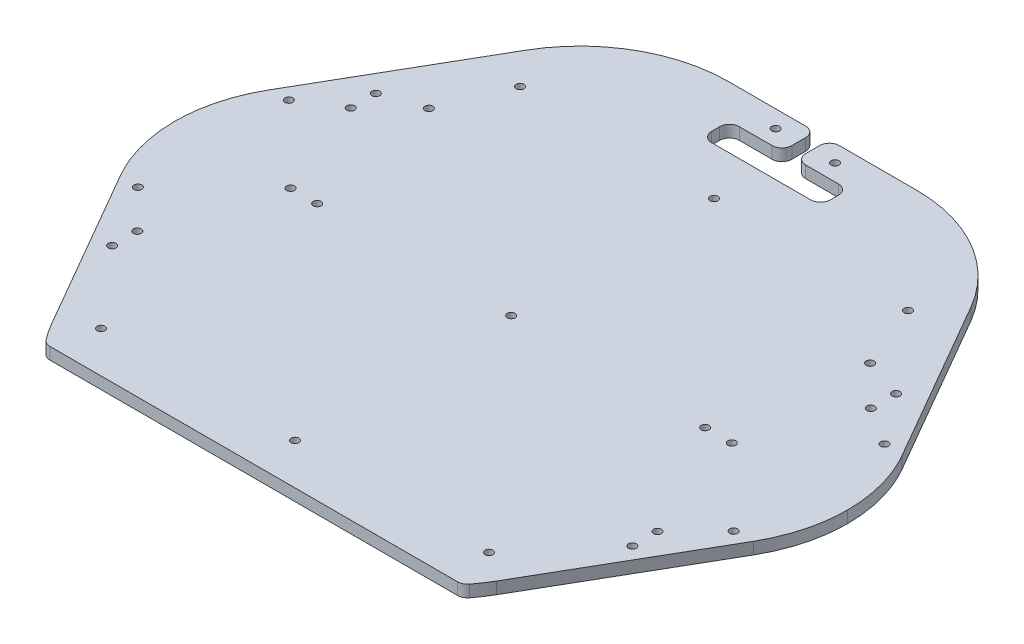
from build123d import *

# Parameters (mm, degrees)
BOSS_EXTRUDE1_DEPTH        = 6
CUT_EXTRUDE1_DEPTH         = 7.0000001
M3_5_CLEARANCE_HOLE1_D     = 3.949564791
M3_5_CLEARANCE_HOLE1_DEPTH = 6.000055
FILLET1_R                  = 5.02065441
FILLET2_R                  = 74.958489821


with BuildPart() as part:
    # Sketch1 → Boss-Extrude1 (new body)
    with BuildSketch(Plane(origin=(0, 6, 0), x_dir=(1, 0, 0), z_dir=(0, 1, 0))):
        with BuildLine():
            Line((112.451900879, -119.772412512), (159.951903815, -37.500000848))
            add(Edge.make_bspline(
                [(159.951903815, -37.500000848), (162.089841538, -33.796778918), (165.842589826, -25.786061926), (169.244511458, -13.089917553), (169.999894602, -4.276058992), (169.999997188, -5.864e-06)],
                knots=[2.617993882, 2.617993882, 2.617993882, 2.617993882, 2.789036145, 2.970550387, 3.141592649, 3.141592649, 3.141592649, 3.141592649], degree=3))
            add(Edge.make_bspline(
                [(169.999997188, -5.864e-06), (169.999894602, 4.276047264), (169.244511458, 13.089905825), (165.842589826, 25.786050198), (162.089841538, 33.79676719), (159.951903815, 37.49998912)],
                knots=[3.141592658, 3.141592658, 3.141592658, 3.141592658, 3.31263492, 3.494149162, 3.665191425, 3.665191425, 3.665191425, 3.665191425], degree=3))
            Line((159.951903815, 37.49998912), (90.801278878, 157.272408343))
            Line((90.801278878, 157.272408343), (-90.8012615, 157.272408343))
            Line((-90.8012615, 157.272408343), (-159.951896595, 37.499994984))
            add(Edge.make_bspline(
                [(-159.951896595, 37.499994984), (-162.089834317, 33.796773054), (-165.842582605, 25.786056062), (-169.244504237, 13.08991169), (-169.999887381, 4.276053128), (-169.999989967, 0)],
                knots=[5.759586536, 5.759586536, 5.759586536, 5.759586536, 5.930628798, 6.11214304, 6.283185303, 6.283185303, 6.283185303, 6.283185303], degree=3))
            add(Edge.make_bspline(
                [(-169.999989967, 0), (-169.999887381, -4.276053128), (-169.244504237, -13.089911689), (-165.842582605, -25.786056062), (-162.089834317, -33.796773054), (-159.951896595, -37.499994984)],
                knots=[6.283185312, 6.283185312, 6.283185312, 6.283185312, 6.454227574, 6.635741816, 6.806784078, 6.806784078, 6.806784078, 6.806784078], degree=3))
            Line((-159.951896595, -37.499994984), (-112.451903815, -119.772412512))
            add(Edge.make_bspline(
                [(-112.451903815, -119.772412512), (-110.697042547, -122.811840435), (-108.72856528, -125.72791615), (-106.565705299, -128.491919084), (-106.17234227, -128.994613005), (-105.778979241, -129.497306926), (-105.385616213, -130.000000848)],
                knots=[0.523598778, 0.523598778, 0.523598778, 0.523598778, 0.663984963, 0.663984963, 0.663984963, 0.689517237, 0.689517237, 0.689517237, 0.689517237], degree=3))
            Line((-105.385616213, -130.000000848), (105.385613276, -130.000000848))
            add(Edge.make_bspline(
                [(105.385613276, -130.000000848), (105.778976305, -129.497306926), (106.172339333, -128.994613005), (106.565702362, -128.491919084), (108.728562343, -125.72791615), (110.69703961, -122.811840435), (112.451900879, -119.772412512)],
                knots=[2.452075416, 2.452075416, 2.452075416, 2.452075416, 2.477607691, 2.477607691, 2.477607691, 2.617993876, 2.617993876, 2.617993876, 2.617993876], degree=3))
        make_face()
    extrude(amount=-BOSS_EXTRUDE1_DEPTH)

    # Sketch2 → Cut-Extrude1 (cut, through all)
    with BuildSketch(Plane.XZ):
        Polygon((3.5, -157.27241336), (3.5, -140.27241336), (30, -140.27241336), (30, -126.27241336), (-30, -126.27241336), (-30, -140.27241336), (-3.5, -140.27241336), (-3.5, -157.27241336), align=None)
    extrude(amount=-CUT_EXTRUDE1_DEPTH, mode=Mode.SUBTRACT)

    # M3.5 Clearance Hole1
    with Locations(Plane(origin=(0, 0, 0), x_dir=(-1, 0, 0), z_dir=(0, -1, 0))):
        with Locations((98, -109.219962871), (-98, 102.438237129), (98, 102.438237129), (0, 102.438237129), (0, -109.219962871), (0, 3.7129e-05), (-97.9932, -3.7129e-05), (97.9932, -3.7129e-05), (111.4552, 69.849962871), (111.4552, -3.7129e-05), (-111.4552, 69.849962871), (-111.4552, -3.7129e-05), (-98, -109.219962871), (131.4, 50.300037129), (-131.4, 50.300037129), (131.4, -70.199962871), (-131.4, -70.199962871), (131.4, 63.000037129), (-131.4, 63.000037129), (131.4, -57.499962871), (-131.4, -57.499962871), (15, 148.600037129), (-15, 148.600037129), (150.47, 38.100037129), (150.47, -38.099962871), (-150.47, 38.100037129), (-150.47, -38.099962871)):
            Hole(M3_5_CLEARANCE_HOLE1_D / 2, depth=M3_5_CLEARANCE_HOLE1_DEPTH)

    # Fillet1
    fillet1_edges = [part.edges().sort_by_distance(p)[0] for p in [
        (-105.385616213, 3, 130.000000848),
        (3.5, 3, -140.27241336),
        (-3.5, 3, -157.272408343),
        (-30, 3, -126.27241336),
        (3.5, 3, -157.272408343),
        (-30, 3, -140.27241336),
        (-3.5, 3, -140.27241336),
        (30, 3, -140.27241336),
        (105.385613276, 3, 130.000000848),
        (30, 3, -126.27241336),
    ]]
    fillet(fillet1_edges, radius=FILLET1_R)

    # Fillet2
    fillet2_edges = [part.edges().sort_by_distance(p)[0] for p in [
        (90.801278878, 3, -157.272408343),
        (-90.8012615, 3, -157.272408343),
    ]]
    fillet(fillet2_edges, radius=FILLET2_R)


solid = part.part
